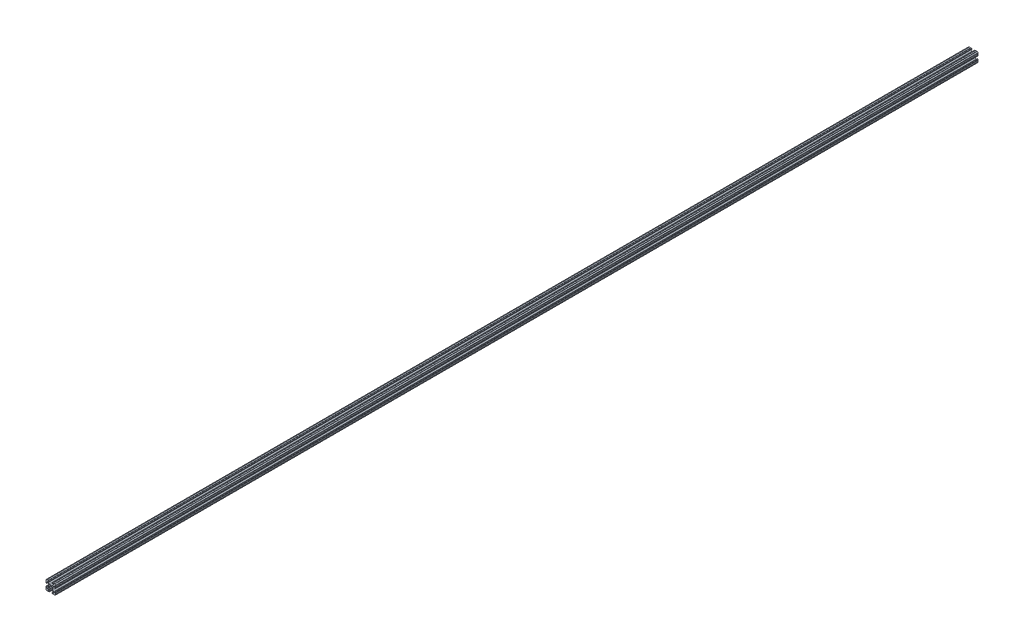
from build123d import *

# Parameters (mm, degrees)
SKETCH1_R           = 2.6035
BOSS_EXTRUDE1_DEPTH = 1219.2


with BuildPart() as part:
    # Sketch1 → Boss-Extrude1 (new body, symmetric)
    with BuildSketch(Plane.XY):
        with BuildLine():
            Line((-7.179650497, -8.645192506), (-3.952270251, -5.423690499))
            ThreePointArc((-3.952270251, -5.423690499), (-2.922936451, -4.736929036), (-1.709253557, -4.4958))
            Line((-1.709253557, -4.4958), (1.709253557, -4.4958))
            ThreePointArc((1.709253557, -4.4958), (2.922936451, -4.736929036), (3.952270251, -5.423690499))
            Line((3.952270251, -5.423690499), (7.179650497, -8.645192506))
            ThreePointArc((7.179650497, -8.645192506), (7.41473083, -9.822813117), (6.416408329, -10.4902))
            Line((6.416408329, -10.4902), (4.287512407, -10.4902))
            ThreePointArc((4.287512407, -10.4902), (3.54574862, -10.79744862), (3.2385, -11.539212407))
            Line((3.2385, -11.539212407), (3.2385, -11.650987593))
            ThreePointArc((3.2385, -11.650987593), (3.54574862, -12.39275138), (4.287512407, -12.7))
            Line((4.287512407, -12.7), (5.317126718, -12.7))
            ThreePointArc((5.317126718, -12.7), (5.825126718, -12.192), (6.333126718, -12.7))
            Line((6.333126718, -12.7), (9.550443118, -12.7))
            ThreePointArc((9.550443118, -12.7), (10.058366869, -12.192000006), (10.566443095, -12.699847501))
            ThreePointArc((10.566443095, -12.699847501), (12.082537762, -12.08250727), (12.699846982, -10.566399977))
            ThreePointArc((12.699846982, -10.566399977), (12.192000006, -10.058323491), (12.7, -9.5504))
            Line((12.7, -9.5504), (12.7, -6.3330836))
            ThreePointArc((12.7, -6.3330836), (12.192, -5.8250836), (12.7, -5.3170836))
            Line((12.7, -5.3170836), (12.7, -4.287469289))
            ThreePointArc((12.7, -4.287469289), (12.39275138, -3.545705502), (11.650987593, -3.238456882))
            Line((11.650987593, -3.238456882), (11.539212407, -3.238456882))
            ThreePointArc((11.539212407, -3.238456882), (10.79744862, -3.545705502), (10.4902, -4.287469289))
            Line((10.4902, -4.287469289), (10.4902, -6.402089023))
            ThreePointArc((10.4902, -6.402089023), (9.856505071, -7.351067942), (8.737131347, -7.129408934))
            Line((8.737131347, -7.129408934), (5.441005833, -3.840816462))
            ThreePointArc((5.441005833, -3.840816462), (4.750877967, -2.809883091), (4.5085, -1.593185507))
            Line((4.5085, -1.593185507), (4.5085, 1.593185507))
            ThreePointArc((4.5085, 1.593185507), (4.750877967, 2.809883091), (5.441005833, 3.840816462))
            Line((5.441005833, 3.840816462), (8.737131347, 7.129408934))
            ThreePointArc((8.737131347, 7.129408934), (9.856505071, 7.351067942), (10.4902, 6.402089023))
            Line((10.4902, 6.402089023), (10.4902, 4.287469289))
            ThreePointArc((10.4902, 4.287469289), (10.79744862, 3.545705502), (11.539212407, 3.238456882))
            Line((11.539212407, 3.238456882), (11.650987593, 3.238456882))
            ThreePointArc((11.650987593, 3.238456882), (12.39275138, 3.545705502), (12.7, 4.287469289))
            Line((12.7, 4.287469289), (12.7, 5.3170836))
            ThreePointArc((12.7, 5.3170836), (12.192, 5.8250836), (12.7, 6.3330836))
            Line((12.7, 6.3330836), (12.7, 9.5504))
            ThreePointArc((12.7, 9.5504), (12.192000006, 10.058323491), (12.699846982, 10.566399977))
            ThreePointArc((12.699846982, 10.566399977), (12.082537762, 12.08250727), (10.566443095, 12.699847501))
            ThreePointArc((10.566443095, 12.699847501), (10.058366869, 12.192000006), (9.550443118, 12.7))
            Line((9.550443118, 12.7), (6.333126718, 12.7))
            ThreePointArc((6.333126718, 12.7), (5.825126718, 12.192), (5.317126718, 12.7))
            Line((5.317126718, 12.7), (4.287512407, 12.7))
            ThreePointArc((4.287512407, 12.7), (3.54574862, 12.39275138), (3.2385, 11.650987593))
            Line((3.2385, 11.650987593), (3.2385, 11.539212407))
            ThreePointArc((3.2385, 11.539212407), (3.54574862, 10.79744862), (4.287512407, 10.4902))
            Line((4.287512407, 10.4902), (6.476788598, 10.4902))
            ThreePointArc((6.476788598, 10.4902), (7.432222385, 9.85140422), (7.207036008, 8.724370562))
            Line((7.207036008, 8.724370562), (3.898272566, 5.423169045))
            ThreePointArc((3.898272566, 5.423169045), (2.869120213, 4.736787962), (1.655778399, 4.4958))
            Line((1.655778399, 4.4958), (-1.655778399, 4.4958))
            ThreePointArc((-1.655778399, 4.4958), (-2.869120213, 4.736787962), (-3.898272566, 5.423169045))
            Line((-3.898272566, 5.423169045), (-7.207036008, 8.724370562))
            ThreePointArc((-7.207036008, 8.724370562), (-7.432222385, 9.85140422), (-6.476788598, 10.4902))
            Line((-6.476788598, 10.4902), (-4.287512407, 10.4902))
            ThreePointArc((-4.287512407, 10.4902), (-3.54574862, 10.79744862), (-3.2385, 11.539212407))
            Line((-3.2385, 11.539212407), (-3.2385, 11.650987593))
            ThreePointArc((-3.2385, 11.650987593), (-3.54574862, 12.39275138), (-4.287512407, 12.7))
            Line((-4.287512407, 12.7), (-5.317126718, 12.7))
            ThreePointArc((-5.317126718, 12.7), (-5.825126718, 12.192), (-6.333126718, 12.7))
            Line((-6.333126718, 12.7), (-9.550443118, 12.7))
            ThreePointArc((-9.550443118, 12.7), (-10.058366869, 12.192000006), (-10.566443095, 12.699847501))
            ThreePointArc((-10.566443095, 12.699847501), (-12.082537762, 12.08250727), (-12.699846982, 10.566399977))
            ThreePointArc((-12.699846982, 10.566399977), (-12.192000006, 10.058323491), (-12.7, 9.5504))
            Line((-12.7, 9.5504), (-12.7, 6.3330836))
            ThreePointArc((-12.7, 6.3330836), (-12.192, 5.8250836), (-12.7, 5.3170836))
            Line((-12.7, 5.3170836), (-12.7, 4.287469289))
            ThreePointArc((-12.7, 4.287469289), (-12.39275138, 3.545705502), (-11.650987593, 3.238456882))
            Line((-11.650987593, 3.238456882), (-11.539212407, 3.238456882))
            ThreePointArc((-11.539212407, 3.238456882), (-10.79744862, 3.545705502), (-10.4902, 4.287469289))
            Line((-10.4902, 4.287469289), (-10.4902, 6.402089023))
            ThreePointArc((-10.4902, 6.402089023), (-9.856505071, 7.351067942), (-8.737131347, 7.129408934))
            Line((-8.737131347, 7.129408934), (-5.441005833, 3.840816462))
            ThreePointArc((-5.441005833, 3.840816462), (-4.750877967, 2.809883091), (-4.5085, 1.593185507))
            Line((-4.5085, 1.593185507), (-4.5085, -1.593185507))
            ThreePointArc((-4.5085, -1.593185507), (-4.750877967, -2.809883091), (-5.441005833, -3.840816462))
            Line((-5.441005833, -3.840816462), (-8.737131347, -7.129408934))
            ThreePointArc((-8.737131347, -7.129408934), (-9.856505071, -7.351067942), (-10.4902, -6.402089023))
            Line((-10.4902, -6.402089023), (-10.4902, -4.287469289))
            ThreePointArc((-10.4902, -4.287469289), (-10.79744862, -3.545705502), (-11.539212407, -3.238456882))
            Line((-11.539212407, -3.238456882), (-11.650987593, -3.238456882))
            ThreePointArc((-11.650987593, -3.238456882), (-12.39275138, -3.545705502), (-12.7, -4.287469289))
            Line((-12.7, -4.287469289), (-12.7, -5.3170836))
            ThreePointArc((-12.7, -5.3170836), (-12.192, -5.8250836), (-12.7, -6.3330836))
            Line((-12.7, -6.3330836), (-12.7, -9.5504))
            ThreePointArc((-12.7, -9.5504), (-12.192000006, -10.058323491), (-12.699846982, -10.566399977))
            ThreePointArc((-12.699846982, -10.566399977), (-12.082537762, -12.08250727), (-10.566443095, -12.699847501))
            ThreePointArc((-10.566443095, -12.699847501), (-10.058366869, -12.192000006), (-9.550443118, -12.7))
            Line((-9.550443118, -12.7), (-6.333126718, -12.7))
            ThreePointArc((-6.333126718, -12.7), (-5.825126718, -12.192), (-5.317126718, -12.7))
            Line((-5.317126718, -12.7), (-4.287512407, -12.7))
            ThreePointArc((-4.287512407, -12.7), (-3.54574862, -12.39275138), (-3.2385, -11.650987593))
            Line((-3.2385, -11.650987593), (-3.2385, -11.539212407))
            ThreePointArc((-3.2385, -11.539212407), (-3.54574862, -10.79744862), (-4.287512407, -10.4902))
            Line((-4.287512407, -10.4902), (-6.416408329, -10.4902))
            ThreePointArc((-6.416408329, -10.4902), (-7.41473083, -9.822813117), (-7.179650497, -8.645192506))
        make_face()
        Circle(SKETCH1_R, mode=Mode.SUBTRACT)
    extrude(amount=BOSS_EXTRUDE1_DEPTH, both=True)


solid = part.part
